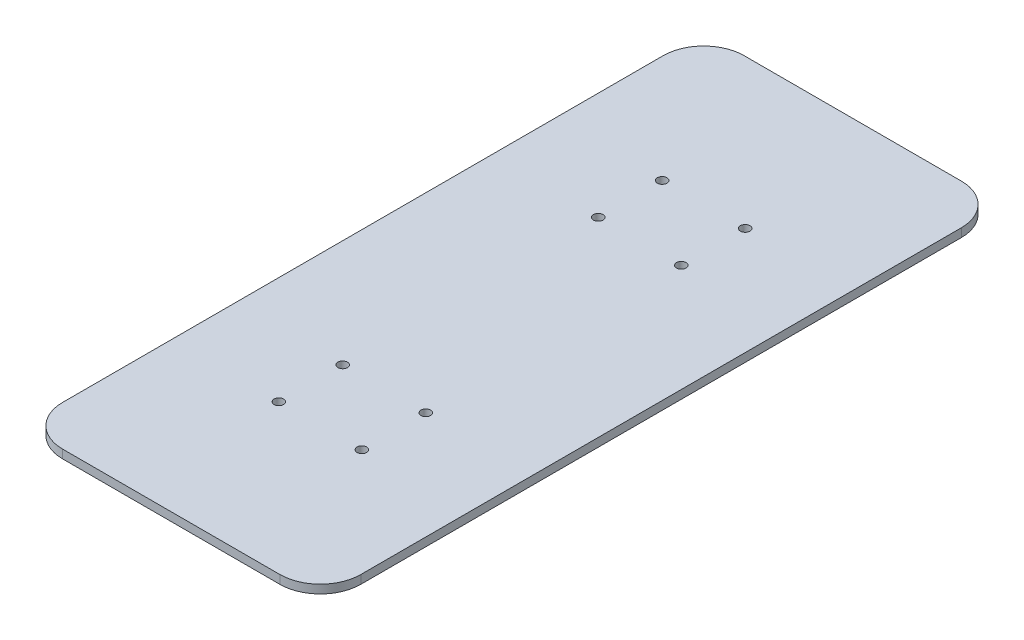
from build123d import *

# Parameters (mm, degrees)
SKETCH1_W           = 140
SKETCH1_H           = 320
BOSS_EXTRUDE1_DEPTH = 4
CUT_EXTRUDE1_REACH  = 6
SKETCH2_R           = 2.25
FILLET1_R           = 19


with BuildPart() as part:
    # Sketch1 → Boss-Extrude1 (new body)
    with BuildSketch(Plane(origin=(0, 0, 0), x_dir=(1, 0, 0), z_dir=(0, 1, 0))):
        with Locations((70, 160)):
            Rectangle(SKETCH1_W, SKETCH1_H)
    extrude(amount=BOSS_EXTRUDE1_DEPTH)

    # Sketch2 → Cut-Extrude1 (cut, up to next)
    with BuildSketch(Plane(origin=(0, 4, 0), x_dir=(1, 0, 0), z_dir=(0, 1, 0)), mode=Mode.PRIVATE) as cut_extrude1_sk1:
        with Locations((89.5, 250)):
            Circle(SKETCH2_R)
    cut_extrude1_tool1 = extrude(cut_extrude1_sk1.sketch, amount=-CUT_EXTRUDE1_REACH, mode=Mode.PRIVATE) & part.part
    add(cut_extrude1_tool1.solids().sort_by_distance((89.5, 4, -250))[0], mode=Mode.SUBTRACT)
    # Sketch2 → Cut-Extrude1 (cut, up to next)
    with BuildSketch(Plane(origin=(0, 4, 0), x_dir=(1, 0, 0), z_dir=(0, 1, 0)), mode=Mode.PRIVATE) as cut_extrude1_sk2:
        with Locations((89.5, 220)):
            Circle(SKETCH2_R)
    cut_extrude1_tool2 = extrude(cut_extrude1_sk2.sketch, amount=-CUT_EXTRUDE1_REACH, mode=Mode.PRIVATE) & part.part
    add(cut_extrude1_tool2.solids().sort_by_distance((89.5, 4, -220))[0], mode=Mode.SUBTRACT)
    # Sketch2 → Cut-Extrude1 (cut, up to next)
    with BuildSketch(Plane(origin=(0, 4, 0), x_dir=(1, 0, 0), z_dir=(0, 1, 0)), mode=Mode.PRIVATE) as cut_extrude1_sk3:
        with Locations((89.5, 100)):
            Circle(SKETCH2_R)
    cut_extrude1_tool3 = extrude(cut_extrude1_sk3.sketch, amount=-CUT_EXTRUDE1_REACH, mode=Mode.PRIVATE) & part.part
    add(cut_extrude1_tool3.solids().sort_by_distance((89.5, 4, -100))[0], mode=Mode.SUBTRACT)
    # Sketch2 → Cut-Extrude1 (cut, up to next)
    with BuildSketch(Plane(origin=(0, 4, 0), x_dir=(1, 0, 0), z_dir=(0, 1, 0)), mode=Mode.PRIVATE) as cut_extrude1_sk4:
        with Locations((89.5, 70)):
            Circle(SKETCH2_R)
    cut_extrude1_tool4 = extrude(cut_extrude1_sk4.sketch, amount=-CUT_EXTRUDE1_REACH, mode=Mode.PRIVATE) & part.part
    add(cut_extrude1_tool4.solids().sort_by_distance((89.5, 4, -70))[0], mode=Mode.SUBTRACT)
    # Sketch2 → Cut-Extrude1 (cut, up to next)
    with BuildSketch(Plane(origin=(0, 4, 0), x_dir=(1, 0, 0), z_dir=(0, 1, 0)), mode=Mode.PRIVATE) as cut_extrude1_sk5:
        with Locations((50.5, 70)):
            Circle(SKETCH2_R)
    cut_extrude1_tool5 = extrude(cut_extrude1_sk5.sketch, amount=-CUT_EXTRUDE1_REACH, mode=Mode.PRIVATE) & part.part
    add(cut_extrude1_tool5.solids().sort_by_distance((50.5, 4, -70))[0], mode=Mode.SUBTRACT)
    # Sketch2 → Cut-Extrude1 (cut, up to next)
    with BuildSketch(Plane(origin=(0, 4, 0), x_dir=(1, 0, 0), z_dir=(0, 1, 0)), mode=Mode.PRIVATE) as cut_extrude1_sk6:
        with Locations((50.5, 100)):
            Circle(SKETCH2_R)
    cut_extrude1_tool6 = extrude(cut_extrude1_sk6.sketch, amount=-CUT_EXTRUDE1_REACH, mode=Mode.PRIVATE) & part.part
    add(cut_extrude1_tool6.solids().sort_by_distance((50.5, 4, -100))[0], mode=Mode.SUBTRACT)
    # Sketch2 → Cut-Extrude1 (cut, up to next)
    with BuildSketch(Plane(origin=(0, 4, 0), x_dir=(1, 0, 0), z_dir=(0, 1, 0)), mode=Mode.PRIVATE) as cut_extrude1_sk7:
        with Locations((50.5, 220)):
            Circle(SKETCH2_R)
    cut_extrude1_tool7 = extrude(cut_extrude1_sk7.sketch, amount=-CUT_EXTRUDE1_REACH, mode=Mode.PRIVATE) & part.part
    add(cut_extrude1_tool7.solids().sort_by_distance((50.5, 4, -220))[0], mode=Mode.SUBTRACT)
    # Sketch2 → Cut-Extrude1 (cut, up to next)
    with BuildSketch(Plane(origin=(0, 4, 0), x_dir=(1, 0, 0), z_dir=(0, 1, 0)), mode=Mode.PRIVATE) as cut_extrude1_sk8:
        with Locations((50.5, 250)):
            Circle(SKETCH2_R)
    cut_extrude1_tool8 = extrude(cut_extrude1_sk8.sketch, amount=-CUT_EXTRUDE1_REACH, mode=Mode.PRIVATE) & part.part
    add(cut_extrude1_tool8.solids().sort_by_distance((50.5, 4, -250))[0], mode=Mode.SUBTRACT)

    # Fillet1
    fillet1_edges = [part.edges().sort_by_distance(p)[0] for p in [
        (0, 2, -320),
        (140, 2, -320),
        (140, 2, 0),
        (0, 2, 0),
    ]]
    fillet(fillet1_edges, radius=FILLET1_R)


solid = part.part
